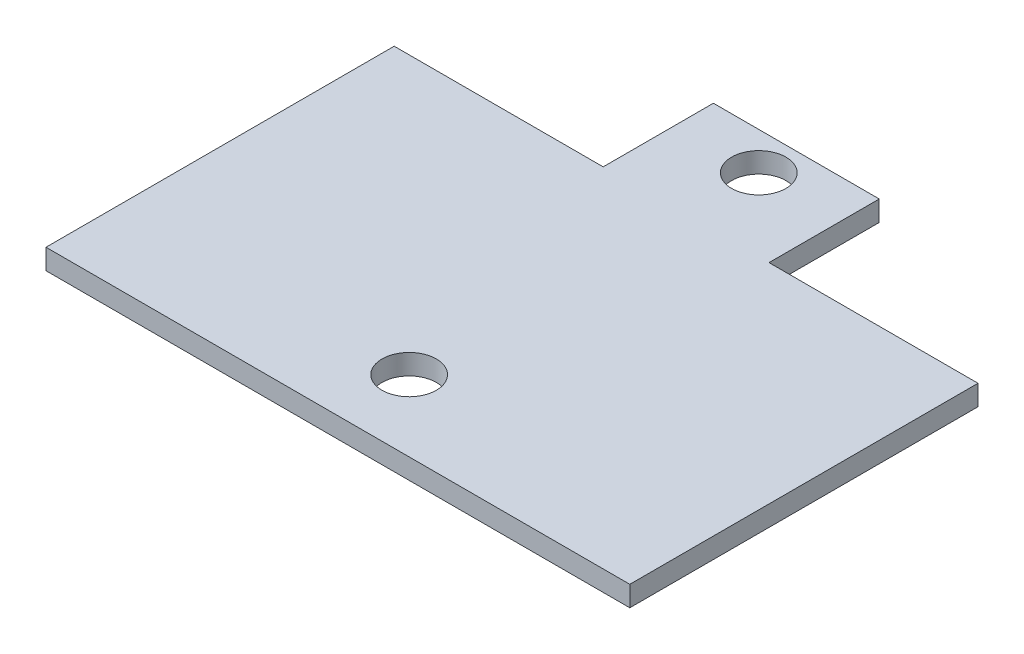
from build123d import *

# Parameters (mm, degrees)
SKETCH_1_R      = 2
EXTRUDE_1_DEPTH = 1.5


with BuildPart() as part:
    # Эскиз1 → Бобышка-Вытянуть1 (new body)
    with BuildSketch(Plane(origin=(0, 0, 0), x_dir=(1, 0, 0), z_dir=(0, 1, 0))):
        Polygon((0, 25.646468405), (15.392280685, 25.646468405), (15.392280685, 33.764912407), (27.607719315, 33.764912407), (27.607719315, 25.646468405), (43, 25.646468405), (43, 0), (0, 0), align=None)
        with Locations((21.5, 5.25)):
            Circle(SKETCH_1_R, mode=Mode.SUBTRACT)
        with Locations((21.5, 31)):
            Circle(SKETCH_1_R, mode=Mode.SUBTRACT)
    extrude(amount=EXTRUDE_1_DEPTH)


solid = part.part
